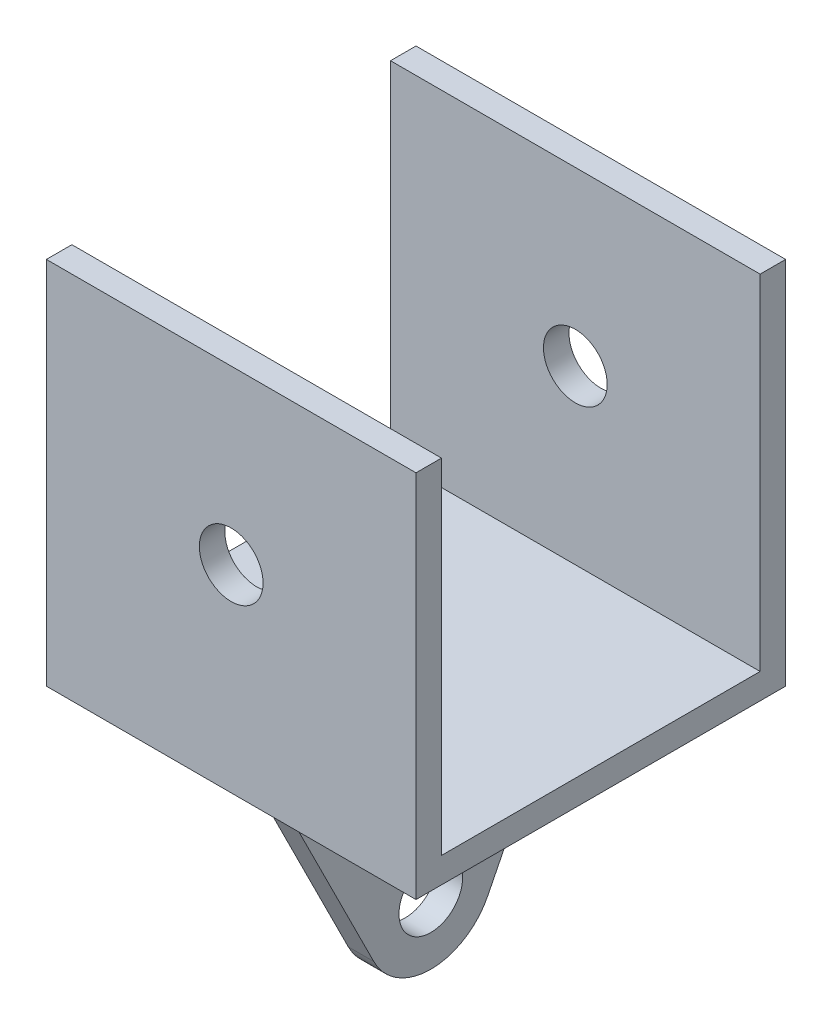
from build123d import *

# Parameters (mm, degrees)
SKETCH1_W                = 29
SKETCH1_H                = 29
BOSS_EXTRUDE1_DEPTH      = 2
SKETCH2_W                = 29
SKETCH2_H                = 2
BOSS_EXTRUDE2_DEPTH      = 27
SKETCH4_R                = 2.5
CUT_EXTRUDE1_DEPTH       = 30
SKETCH6_R                = 2.5
BOSS_EXTRUDE3_DEPTH      = 1
BOSS_EXTRUDE3_DEPTH_BACK = 1


with BuildPart() as part:
    # Sketch1 → Boss-Extrude1 (new body)
    with BuildSketch(Plane(origin=(0, 0, 0), x_dir=(1, 0, 0), z_dir=(0, 1, 0))):
        Rectangle(SKETCH1_W, SKETCH1_H)
    extrude(amount=BOSS_EXTRUDE1_DEPTH)

    # Sketch2 → Boss-Extrude2 (add)
    with BuildSketch(Plane(origin=(0, 2, 0), x_dir=(1, 0, 0), z_dir=(0, 1, 0))):
        with Locations((0, -13.5)):
            Rectangle(SKETCH2_W, SKETCH2_H)
    boss_extrude2 = extrude(amount=BOSS_EXTRUDE2_DEPTH)

    # Mirror1: Boss-Extrude2 across plane
    add(boss_extrude2.mirror(Plane.XY))

    # Sketch4 → Cut-Extrude1 (cut, through all)
    with BuildSketch(Plane.XY.offset(14.5)):
        with Locations((0, 15.5)):
            Circle(SKETCH4_R)
    extrude(amount=-CUT_EXTRUDE1_DEPTH, mode=Mode.SUBTRACT)

    # Sketch6 → Boss-Extrude3 (add, two sides)
    with BuildSketch(Plane(origin=(0, 0, 0), x_dir=(0, 0, -1), z_dir=(1, 0, 0))) as boss_extrude3_sk:
        with BuildLine():
            Line((-12.340534921, 0), (12.662436349, 0))
            Line((12.662436349, 0), (4.632980363, -16.057003584))
            ThreePointArc((4.632980363, -16.057003584), (0.160950714, -18.820723008), (-4.311078935, -16.057003584))
            Line((-4.311078935, -16.057003584), (-12.340534921, 0))
        make_face()
        with Locations((0.160950714, -13.820723008)):
            Circle(SKETCH6_R, mode=Mode.SUBTRACT)
    extrude(amount=BOSS_EXTRUDE3_DEPTH)
    extrude(boss_extrude3_sk.sketch, amount=-BOSS_EXTRUDE3_DEPTH_BACK)


solid = part.part
